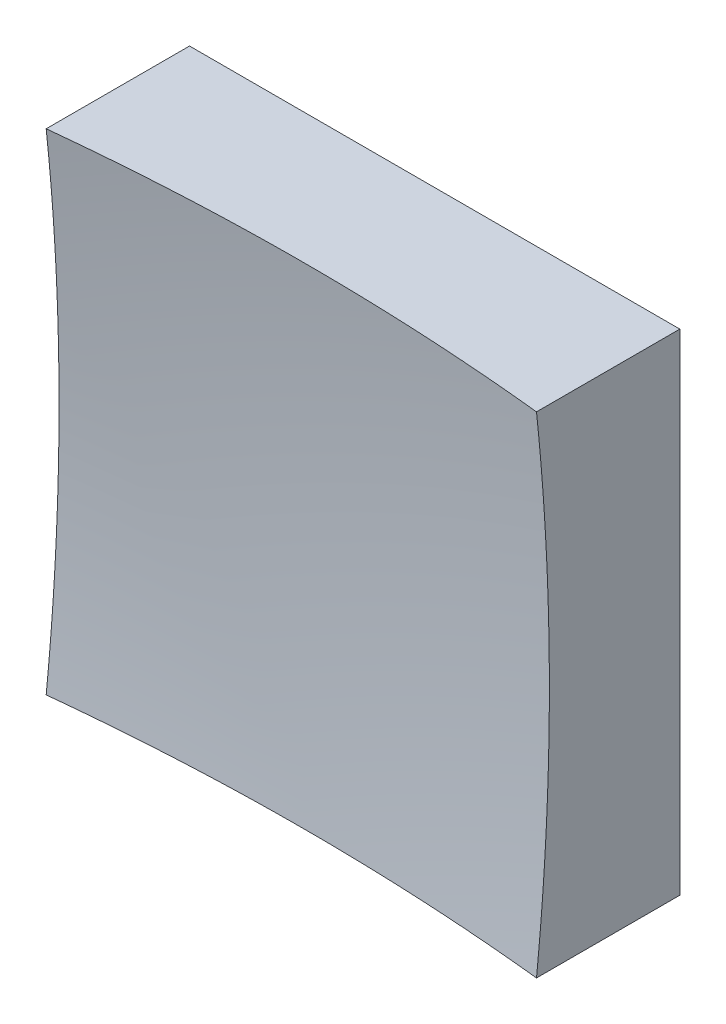
from build123d import *

# Parameters (mm, degrees)
SKETCH_1_W      = 12.5
SKETCH_1_H      = 12.5
EXTRUDE_1_DEPTH = 10


with BuildPart() as part:
    # 草图1 → 凸台-拉伸1 (new body)
    with BuildSketch(Plane.XY):
        Rectangle(SKETCH_1_W, SKETCH_1_H)
    extrude(amount=EXTRUDE_1_DEPTH)

    # 草图2 → 切除-旋转2 (revolve, cut)
    with BuildSketch(Plane(origin=(0, 0, 0), x_dir=(1, 0, 0), z_dir=(0, 1, 0))):
        with BuildLine():
            Line((58.490727709, -49.627088122), (0, -49.627088122))
            Line((0, -49.627088122), (0, -3))
            ThreePointArc((0, -3), (37.400703786, -16.083186848), (58.490727709, -49.627088122))
        make_face()
    revolve(axis=Axis((0, 0, 49.627088122), (0, 0, -1)), mode=Mode.SUBTRACT)


solid = part.part
